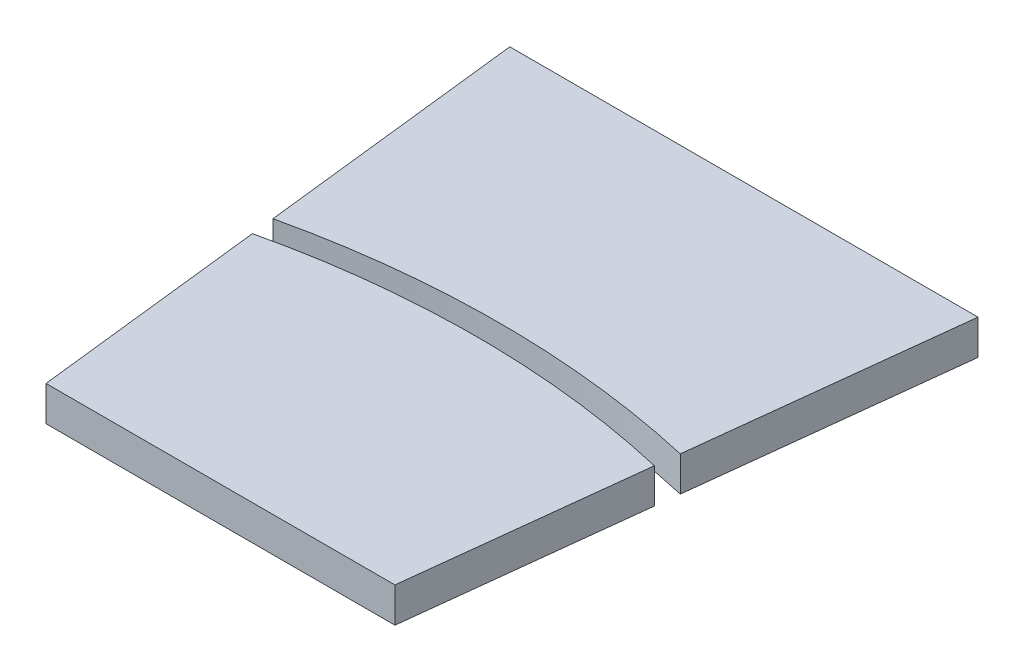
from build123d import *

# Parameters (mm, degrees)
BOSS_EXTRUDE1_DEPTH     = 3
CUT_EXTRUDE1_DEPTH      = 1
CUT_EXTRUDE1_DEPTH_BACK = 4


with BuildPart() as part:
    # Sketch1 → Boss-Extrude1 (new body)
    with BuildSketch(Plane(origin=(0, 0, 0), x_dir=(1, 0, 0), z_dir=(0, 1, 0))):
        Polygon((-20.127102374, 99.5), (-15, 54.5), (0, 54.5), (0, 99.5), align=None)
    boss_extrude1 = extrude(amount=BOSS_EXTRUDE1_DEPTH)

    # Mirror2: Boss-Extrude1 across plane
    add(boss_extrude1.mirror(Plane(origin=(0, 0, 0), x_dir=(0, 0, 1), z_dir=(1, 0, 0))))

    # Sketch2 → Cut-Extrude1 (cut, two sides)
    with BuildSketch(Plane(origin=(0, 3, 0), x_dir=(1, 0, 0), z_dir=(0, 1, 0))) as cut_extrude1_sk:
        with BuildLine():
            Line((-17.281279071, 74.522529437), (-17.509137333, 76.522415735))
            ThreePointArc((-17.509137333, 76.522415735), (0, 78.5), (17.509137333, 76.522415735))
            Line((17.509137333, 76.522415735), (17.281279071, 74.522529437))
            ThreePointArc((17.281279071, 74.522529437), (0, 76.5), (-17.281279071, 74.522529437))
        make_face()
    extrude(amount=CUT_EXTRUDE1_DEPTH, mode=Mode.SUBTRACT)
    extrude(cut_extrude1_sk.sketch, amount=-CUT_EXTRUDE1_DEPTH_BACK, mode=Mode.SUBTRACT)


solid = part.part
